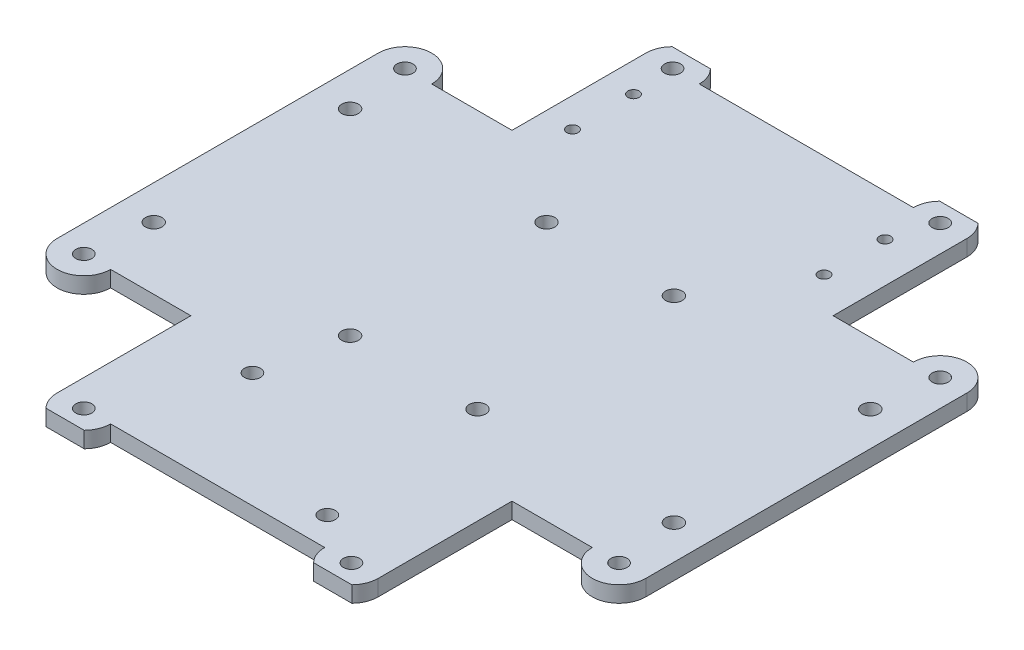
from build123d import *

# Parameters (mm, degrees)
SKETCH1_W               = 110
SKETCH1_H               = 110
SKETCH1_R               = 1.55
SKETCH1_R_2             = 1.05
SKETCH1_R_3             = 1.5
BOSS_EXTRUDE2_DEPTH     = 3
SKETCH3_W               = 25
SKETCH3_H               = 25
CUT_EXTRUDE1_DEPTH      = 3
SKETCH4_R               = 5
BOSS_EXTRUDE3_DEPTH     = 3
SKETCH5_R               = 1.5
CUT_EXTRUDE3_DEPTH      = 4
SKETCH6_W               = 60
SKETCH6_H               = 1.5
CUT_EXTRUDE6_DEPTH      = 1
CUT_EXTRUDE6_DEPTH_BACK = 4


with BuildPart() as part:
    # Sketch1 → Boss-Extrude2 (new body)
    with BuildSketch(Plane(origin=(0, 0, 0), x_dir=(1, 0, 0), z_dir=(0, 1, 0))):
        Rectangle(SKETCH1_W, SKETCH1_H)
        with Locations((-48.6, 18.35)):
            Circle(SKETCH1_R, mode=Mode.SUBTRACT)
        with Locations((-11.9, 18.35)):
            Circle(SKETCH1_R, mode=Mode.SUBTRACT)
        with Locations((-11.9, -18.35)):
            Circle(SKETCH1_R, mode=Mode.SUBTRACT)
        with Locations((-48.6, -18.35)):
            Circle(SKETCH1_R, mode=Mode.SUBTRACT)
        with Locations((48.6, -18.35)):
            Circle(SKETCH1_R, mode=Mode.SUBTRACT)
        with Locations((11.9, -18.35)):
            Circle(SKETCH1_R, mode=Mode.SUBTRACT)
        with Locations((11.9, 18.35)):
            Circle(SKETCH1_R, mode=Mode.SUBTRACT)
        with Locations((48.6, 18.35)):
            Circle(SKETCH1_R, mode=Mode.SUBTRACT)
        with Locations((-24.5, 47.2)):
            Circle(SKETCH1_R_2, mode=Mode.SUBTRACT)
        with Locations((-24.5, 35.8)):
            Circle(SKETCH1_R_2, mode=Mode.SUBTRACT)
        with Locations((22.5, 47.2)):
            Circle(SKETCH1_R_2, mode=Mode.SUBTRACT)
        with Locations((22.5, 35.8)):
            Circle(SKETCH1_R_2, mode=Mode.SUBTRACT)
        with Locations((-15, -33.5)):
            Circle(SKETCH1_R_3, mode=Mode.SUBTRACT)
        with Locations((15, -49.5)):
            Circle(SKETCH1_R_3, mode=Mode.SUBTRACT)
    extrude(amount=BOSS_EXTRUDE2_DEPTH)

    # Sketch3 → Cut-Extrude1 (cut)
    with BuildSketch(Plane(origin=(0, 3, 0), x_dir=(1, 0, 0), z_dir=(0, 1, 0))):
        with Locations((42.5, 42.5)):
            Rectangle(SKETCH3_W, SKETCH3_H)
        with Locations((-42.5, 42.5)):
            Rectangle(SKETCH3_W, SKETCH3_H)
        with Locations((42.5, -42.5)):
            Rectangle(SKETCH3_W, SKETCH3_H)
        with Locations((-42.5, -42.5)):
            Rectangle(SKETCH3_W, SKETCH3_H)
    extrude(amount=-CUT_EXTRUDE1_DEPTH, mode=Mode.SUBTRACT)

    # Sketch4 → Boss-Extrude3 (add)
    with BuildSketch(Plane(origin=(0, 3, 0), x_dir=(1, 0, 0), z_dir=(0, 1, 0))):
        with Locations((50, 30)):
            Circle(SKETCH4_R)
        with Locations((-50, 30)):
            Circle(SKETCH4_R)
        with Locations((50, -30)):
            Circle(SKETCH4_R)
        with Locations((-50, -30)):
            Circle(SKETCH4_R)
        with Locations((-25, 55)):
            Circle(SKETCH4_R)
        with Locations((25, 55)):
            Circle(SKETCH4_R)
        with Locations((25, -55)):
            Circle(SKETCH4_R)
        with Locations((-25, -55)):
            Circle(SKETCH4_R)
    extrude(amount=-BOSS_EXTRUDE3_DEPTH)

    # Sketch5 → Cut-Extrude3 (cut, through all)
    with BuildSketch(Plane(origin=(0, 3, 0), x_dir=(1, 0, 0), z_dir=(0, 1, 0))):
        with Locations((50, 30)):
            Circle(SKETCH5_R)
        with Locations((50, -30)):
            Circle(SKETCH5_R)
        with Locations((-50, -30)):
            Circle(SKETCH5_R)
        with Locations((-50, 30)):
            Circle(SKETCH5_R)
        with Locations((-25, 55)):
            Circle(SKETCH5_R)
        with Locations((25, 55)):
            Circle(SKETCH5_R)
        with Locations((25, -55)):
            Circle(SKETCH5_R)
        with Locations((-25, -55)):
            Circle(SKETCH5_R)
    extrude(amount=-CUT_EXTRUDE3_DEPTH, mode=Mode.SUBTRACT)

    # Sketch6 → Cut-Extrude6 (cut, two sides)
    with BuildSketch(Plane(origin=(0, 3, 0), x_dir=(1, 0, 0), z_dir=(0, 1, 0))) as cut_extrude6_sk:
        with Locations((0, 59.25)):
            Rectangle(SKETCH6_W, SKETCH6_H)
        with Locations((0, -59.25)):
            Rectangle(SKETCH6_W, SKETCH6_H)
    extrude(amount=CUT_EXTRUDE6_DEPTH, mode=Mode.SUBTRACT)
    extrude(cut_extrude6_sk.sketch, amount=-CUT_EXTRUDE6_DEPTH_BACK, mode=Mode.SUBTRACT)


solid = part.part
